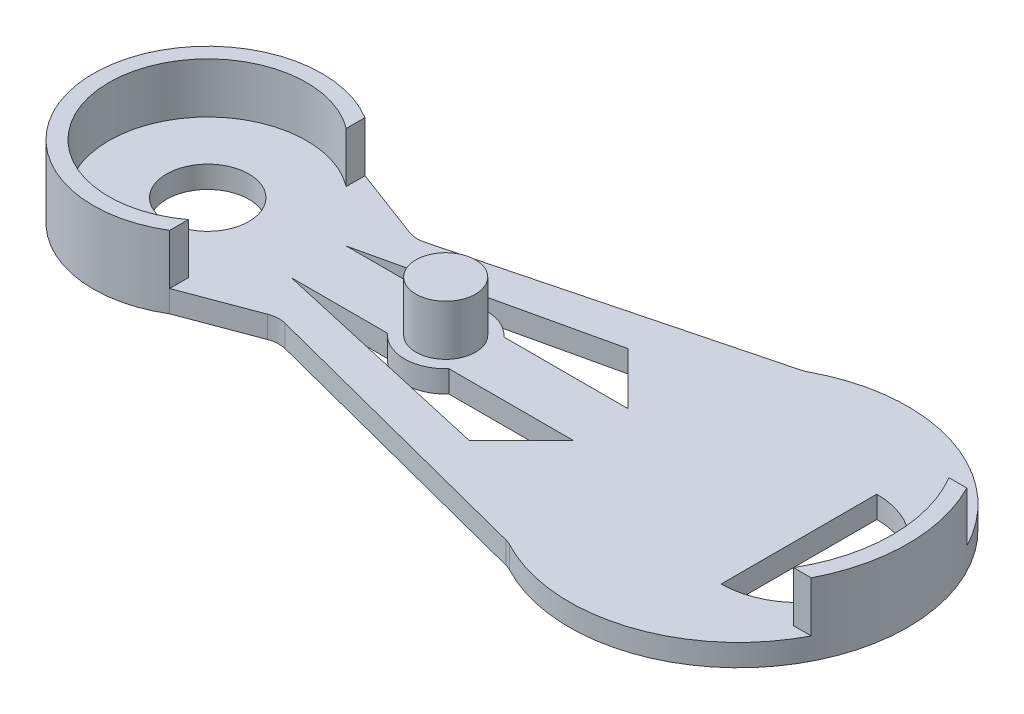
from build123d import *

# Parameters (mm, degrees)
SKETCH1_R           = 4.5
BOSS_EXTRUDE1_DEPTH = 2.4
FILLET1_R           = 3
SKETCH2_R           = 3.25
BOSS_EXTRUDE2_DEPTH = 5.5


with BuildPart() as part:
    # Sketch1 → Boss-Extrude1 (new body)
    with BuildSketch(Plane(origin=(0, 0, 0), x_dir=(1, 0, 0), z_dir=(0, 1, 0))):
        with BuildLine():
            ThreePointArc((-48.371159118, 10.670216357), (-67.382417284, 0), (-48.371159118, -10.670216357))
            Line((-48.371159118, -10.670216357), (-39.699633202, -7.41775842))
            Line((-39.699633202, -7.41775842), (-5.857739229, -16.176946436))
            ThreePointArc((-5.857739229, -16.176946436), (21.617582716, 0), (-5.857739229, 16.176946436))
            Line((-5.857739229, 16.176946436), (-39.699633202, 7.41775842))
            Line((-39.699633202, 7.41775842), (-48.371159118, 10.670216357))
        make_face()
        with BuildLine():
            Line((-11.950545902, 3), (-25.528315318, 3))
            ThreePointArc((-25.528315318, 3), (-28.882417284, 4.5), (-32.23651925, 3))
            Line((-32.23651925, 3), (-42.747756184, 3))
            Line((-42.747756184, 3), (-17.634945081, 8.68439918))
            Line((-17.634945081, 8.68439918), (-11.950545902, 3))
        make_face(mode=Mode.SUBTRACT)
        with BuildLine():
            Line((9.717339795, -8.5), (9.717339795, 8.5))
            ThreePointArc((9.717339795, 8.5), (18.217339795, 0), (9.717339795, -8.5))
        make_face(mode=Mode.SUBTRACT)
        with BuildLine():
            Line((-42.747756184, -3), (-32.23651925, -3))
            ThreePointArc((-32.23651925, -3), (-28.882417284, -4.5), (-25.528315318, -3))
            Line((-25.528315318, -3), (-11.950545902, -3))
            Line((-11.950545902, -3), (-17.634945081, -8.68439918))
            Line((-17.634945081, -8.68439918), (-42.747756184, -3))
        make_face(mode=Mode.SUBTRACT)
        with Locations((-54.882417284, 0)):
            Circle(SKETCH1_R, mode=Mode.SUBTRACT)
    extrude(amount=BOSS_EXTRUDE1_DEPTH)

    # Fillet1
    fillet1_edges = [part.edges().sort_by_distance(p)[0] for p in [
        (-39.699633202, 1.2, -7.41775842),
        (-5.857739229, 1.2, -16.176946436),
        (-5.857739229, 1.2, 16.176946436),
        (-39.699633202, 1.2, 7.41775842),
    ]]
    fillet(fillet1_edges, radius=FILLET1_R)

    # Sketch2 → Boss-Extrude2 (add)
    with BuildSketch(Plane(origin=(0, 2.4, 0), x_dir=(1, 0, 0), z_dir=(0, 1, 0))):
        with Locations((-28.882417284, 0)):
            Circle(SKETCH2_R)
        with BuildLine():
            Line((-48.371159118, 8.621240559), (-48.371159118, 10.670216357))
            ThreePointArc((-48.371159118, 10.670216357), (-67.382417284, 0), (-48.371159118, -10.670216357))
            Line((-48.371159118, -10.670216357), (-48.371159118, -8.621240559))
            ThreePointArc((-48.371159118, -8.621240559), (-65.686225486, 0), (-48.371159118, 8.621240559))
        make_face()
        with BuildLine():
            Line((19.549259441, 8.5), (17.608614425, 8.5))
            ThreePointArc((17.608614425, 8.5), (19.917582716, 0), (17.608614425, -8.5))
            Line((17.608614425, -8.5), (19.549259441, -8.5))
            ThreePointArc((19.549259441, -8.5), (21.617582716, 0), (19.549259441, 8.5))
        make_face()
    extrude(amount=BOSS_EXTRUDE2_DEPTH)


solid = part.part
